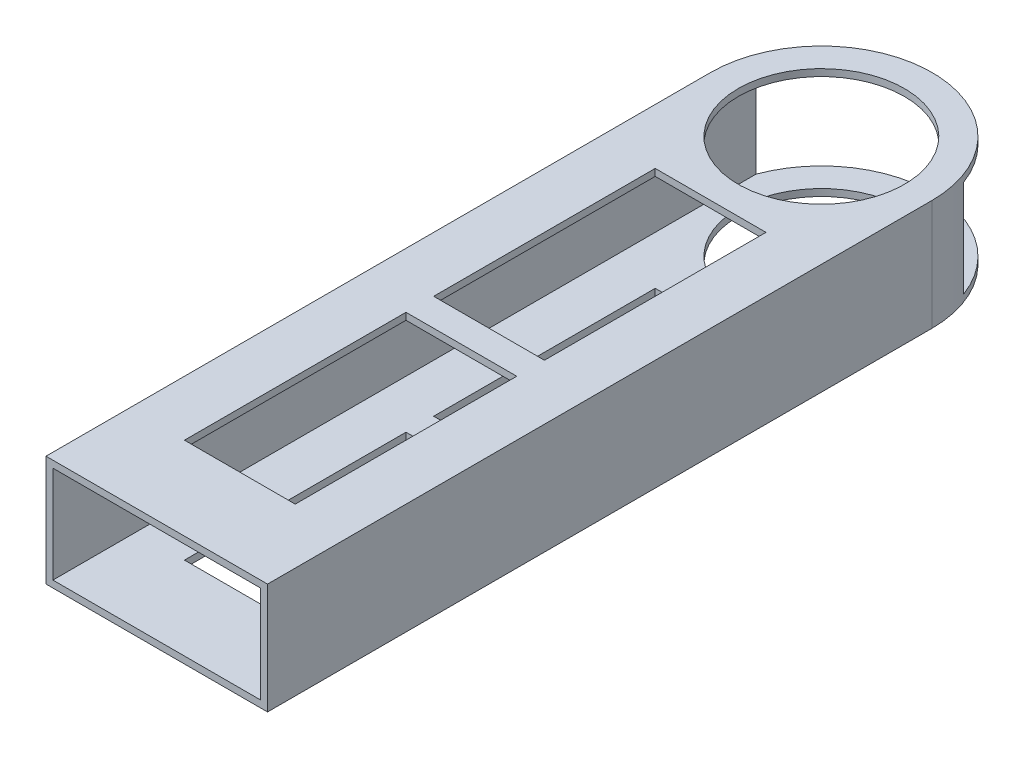
from build123d import *

# Parameters (mm, degrees)
SKETCH1_W           = 50.8
SKETCH1_H           = 25.4
SKETCH1_W_2         = 47.625
SKETCH1_H_2         = 22.225
BOSS_EXTRUDE1_DEPTH = 177.8
CUT_EXTRUDE1_REACH  = 183.392
SKETCH2_W           = 25.4
SKETCH2_H           = 50.8


with BuildPart() as part:
    # Sketch1 → Boss-Extrude1 (new body)
    with BuildSketch(Plane.XY):
        Rectangle(SKETCH1_W, SKETCH1_H)
        Rectangle(SKETCH1_W_2, SKETCH1_H_2, mode=Mode.SUBTRACT)
    extrude(amount=BOSS_EXTRUDE1_DEPTH)

    # Cut-Extrude1: up to this face of the body (flat: up to its plane)
    cut_extrude1_end = Plane(part.part.faces().sort_by_distance((0, -12.7, 88.9))[0])
    # Sketch2 → Cut-Extrude1 (cut, up to the picked face)
    with BuildSketch(Plane(origin=(0, 12.7, 0), x_dir=(1, 0, 0), z_dir=(0, 1, 0)), mode=Mode.PRIVATE) as cut_extrude1_sk1:
        with BuildLine():
            ThreePointArc((-25.4, -25.4), (-17.960512214, -7.439487729), (8.1e-08, 0))
            Line((8.1e-08, 0), (-25.4, 0))
            Line((-25.4, 0), (-25.4, -25.4))
        make_face()
    cut_extrude1_tool1 = split(extrude(cut_extrude1_sk1.sketch, amount=-CUT_EXTRUDE1_REACH, mode=Mode.PRIVATE), bisect_by=cut_extrude1_end, keep=Keep.BOTH, mode=Mode.PRIVATE)
    # Sketch2 → Cut-Extrude1 (cut, up to the picked face)
    with BuildSketch(Plane(origin=(0, 12.7, 0), x_dir=(1, 0, 0), z_dir=(0, 1, 0)), mode=Mode.PRIVATE) as cut_extrude1_sk2:
        with BuildLine():
            ThreePointArc((-19.05, -25.4), (0, -44.45), (19.05, -25.4))
            Line((19.05, -25.4), (-19.05, -25.4))
        make_face()
    cut_extrude1_tool2 = split(extrude(cut_extrude1_sk2.sketch, amount=-CUT_EXTRUDE1_REACH, mode=Mode.PRIVATE), bisect_by=cut_extrude1_end, keep=Keep.BOTH, mode=Mode.PRIVATE)
    # Sketch2 → Cut-Extrude1 (cut, up to the picked face)
    with BuildSketch(Plane(origin=(0, 12.7, 0), x_dir=(1, 0, 0), z_dir=(0, 1, 0)), mode=Mode.PRIVATE) as cut_extrude1_sk3:
        with BuildLine():
            Line((-19.05, -25.4), (19.05, -25.4))
            ThreePointArc((19.05, -25.4), (0, -6.35), (-19.05, -25.4))
        make_face()
    cut_extrude1_tool3 = split(extrude(cut_extrude1_sk3.sketch, amount=-CUT_EXTRUDE1_REACH, mode=Mode.PRIVATE), bisect_by=cut_extrude1_end, keep=Keep.BOTH, mode=Mode.PRIVATE)
    # Sketch2 → Cut-Extrude1 (cut, up to the picked face)
    with BuildSketch(Plane(origin=(0, 12.7, 0), x_dir=(1, 0, 0), z_dir=(0, 1, 0)), mode=Mode.PRIVATE) as cut_extrude1_sk4:
        with BuildLine():
            ThreePointArc((8.1e-08, 0), (17.960512271, -7.439487786), (25.4, -25.4))
            Line((25.4, -25.4), (25.4, 0))
            Line((25.4, 0), (8.1e-08, 0))
        make_face()
    cut_extrude1_tool4 = split(extrude(cut_extrude1_sk4.sketch, amount=-CUT_EXTRUDE1_REACH, mode=Mode.PRIVATE), bisect_by=cut_extrude1_end, keep=Keep.BOTH, mode=Mode.PRIVATE)
    # Sketch2 → Cut-Extrude1 (cut, up to the picked face)
    with BuildSketch(Plane(origin=(0, 12.7, 0), x_dir=(1, 0, 0), z_dir=(0, 1, 0)), mode=Mode.PRIVATE) as cut_extrude1_sk5:
        with BuildLine():
            ThreePointArc((-19.05, -25.4), (0, -44.45), (19.05, -25.4))
            Line((19.05, -25.4), (-19.05, -25.4))
        make_face()
    cut_extrude1_tool5 = split(extrude(cut_extrude1_sk5.sketch, amount=-CUT_EXTRUDE1_REACH, mode=Mode.PRIVATE), bisect_by=cut_extrude1_end, keep=Keep.BOTH, mode=Mode.PRIVATE)
    # Sketch2 → Cut-Extrude1 (cut, up to the picked face)
    with BuildSketch(Plane(origin=(0, 12.7, 0), x_dir=(1, 0, 0), z_dir=(0, 1, 0)), mode=Mode.PRIVATE) as cut_extrude1_sk6:
        with BuildLine():
            Line((-19.05, -25.4), (19.05, -25.4))
            ThreePointArc((19.05, -25.4), (0, -6.35), (-19.05, -25.4))
        make_face()
    cut_extrude1_tool6 = split(extrude(cut_extrude1_sk6.sketch, amount=-CUT_EXTRUDE1_REACH, mode=Mode.PRIVATE), bisect_by=cut_extrude1_end, keep=Keep.BOTH, mode=Mode.PRIVATE)
    # Sketch2 → Cut-Extrude1 (cut, up to the picked face)
    with BuildSketch(Plane(origin=(0, 12.7, 0), x_dir=(1, 0, 0), z_dir=(0, 1, 0)), mode=Mode.PRIVATE) as cut_extrude1_sk7:
        with Locations((0, -133.35)):
            Rectangle(SKETCH2_W, SKETCH2_H)
    cut_extrude1_tool7 = split(extrude(cut_extrude1_sk7.sketch, amount=-CUT_EXTRUDE1_REACH, mode=Mode.PRIVATE), bisect_by=cut_extrude1_end, keep=Keep.BOTH, mode=Mode.PRIVATE)
    # Sketch2 → Cut-Extrude1 (cut, up to the picked face)
    with BuildSketch(Plane(origin=(0, 12.7, 0), x_dir=(1, 0, 0), z_dir=(0, 1, 0)), mode=Mode.PRIVATE) as cut_extrude1_sk8:
        with Locations((0, -76.2)):
            Rectangle(SKETCH2_W, SKETCH2_H)
    cut_extrude1_tool8 = split(extrude(cut_extrude1_sk8.sketch, amount=-CUT_EXTRUDE1_REACH, mode=Mode.PRIVATE), bisect_by=cut_extrude1_end, keep=Keep.BOTH, mode=Mode.PRIVATE)
    add(cut_extrude1_tool1.solids().sort_by(Axis((-19.726454, 12.7, 5.673546), (0, -1, 0)))[0], mode=Mode.SUBTRACT)
    add(cut_extrude1_tool2.solids().sort_by(Axis((0, 12.7, 33.485071), (0, -1, 0)))[0], mode=Mode.SUBTRACT)
    add(cut_extrude1_tool3.solids().sort_by(Axis((0, 12.7, 17.314929), (0, -1, 0)))[0], mode=Mode.SUBTRACT)
    add(cut_extrude1_tool4.solids().sort_by(Axis((19.726454, 12.7, 5.673546), (0, -1, 0)))[0], mode=Mode.SUBTRACT)
    add(cut_extrude1_tool5.solids().sort_by(Axis((0, 12.7, 33.485071), (0, -1, 0)))[0], mode=Mode.SUBTRACT)
    add(cut_extrude1_tool6.solids().sort_by(Axis((0, 12.7, 17.314929), (0, -1, 0)))[0], mode=Mode.SUBTRACT)
    add(cut_extrude1_tool7.solids().sort_by(Axis((0, 12.7, 133.35), (0, -1, 0)))[0], mode=Mode.SUBTRACT)
    add(cut_extrude1_tool8.solids().sort_by(Axis((0, 12.7, 76.2), (0, -1, 0)))[0], mode=Mode.SUBTRACT)


solid = part.part
